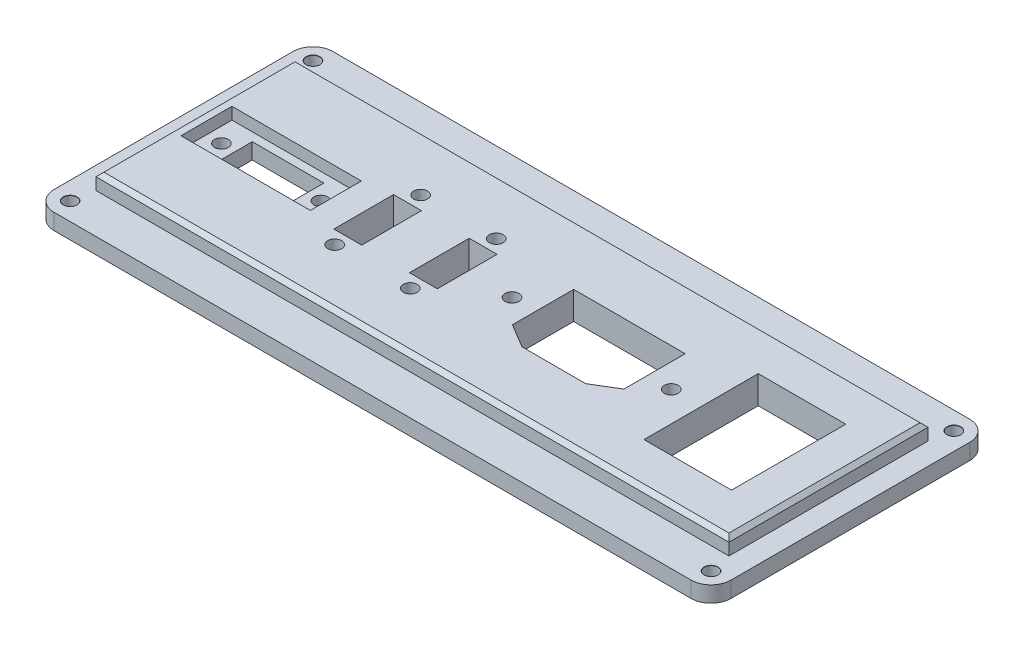
from build123d import *

# Parameters (mm, degrees)
SKETCH1_W                      = 170
SKETCH1_H                      = 70
BOSS_EXTRUDE1_DEPTH            = 4
SKETCH2_W                      = 159
SKETCH2_H                      = 50
BOSS_EXTRUDE2_DEPTH            = 4
M3_CLEARANCE_HOLE1_D           = 3.4
M3_CLEARANCE_HOLE1_CSINK_D     = 3.5
M3_CLEARANCE_HOLE1_CSINK_ANGLE = 90
SKETCH6_R                      = 1.75
SKETCH6_W                      = 18
SKETCH6_H                      = 8.5
SKETCH6_W_2                    = 22
SKETCH6_H_2                    = 28.7
SKETCH6_W_3                    = 7
SKETCH6_H_3                    = 15
CUT_EXTRUDE1_DEPTH             = 9
CUT_EXTRUDE2_START             = -8
SKETCH6_3_W                    = 18
SKETCH6_3_H                    = 8.5
SKETCH6_3_W_2                  = 32.5
SKETCH6_3_H_2                  = 12.8
CUT_EXTRUDE2_DEPTH             = 3
CHAMFER1_SIZE                  = 1
FILLET1_R                      = 5


with BuildPart() as part:
    # Sketch1 → Boss-Extrude1 (new body)
    with BuildSketch(Plane(origin=(0, 0, 0), x_dir=(1, 0, 0), z_dir=(0, 1, 0))):
        Rectangle(SKETCH1_W, SKETCH1_H)
    extrude(amount=BOSS_EXTRUDE1_DEPTH)

    # Sketch2 → Boss-Extrude2 (add)
    with BuildSketch(Plane(origin=(0, 4, 0), x_dir=(1, 0, 0), z_dir=(0, 1, 0))):
        Rectangle(SKETCH2_W, SKETCH2_H)
    extrude(amount=BOSS_EXTRUDE2_DEPTH)

    # M3 Clearance Hole1 (through all)
    with Locations(Plane(origin=(0, 4, 0), x_dir=(1, 0, 0), z_dir=(0, 1, 0))):
        with Locations((80.5, -30.5), (80.5, 30.5), (-80.5, -30.5), (-80.5, 30.5)):
            CounterSinkHole(M3_CLEARANCE_HOLE1_D / 2, M3_CLEARANCE_HOLE1_CSINK_D / 2, counter_sink_angle=M3_CLEARANCE_HOLE1_CSINK_ANGLE)

    # Sketch6 → Cut-Extrude1 (cut, through all)
    with BuildSketch(Plane.XZ):
        with Locations((-48, 0)):
            Circle(SKETCH6_R)
        with Locations((-73, 0)):
            Circle(SKETCH6_R)
        with Locations((-60.5, 0)):
            Rectangle(SKETCH6_W, SKETCH6_H)
        with Locations((-33.75, 10.8)):
            Circle(SKETCH6_R)
        with Locations((-33.75, -10.8)):
            Circle(SKETCH6_R)
        with Locations((-14.75, 10.8)):
            Circle(SKETCH6_R)
        with Locations((-14.75, -10.8)):
            Circle(SKETCH6_R)
        Circle(SKETCH6_R)
        with Locations((58.5, 0)):
            Rectangle(SKETCH6_W_2, SKETCH6_H_2)
        with Locations((-33.75, 0)):
            Rectangle(SKETCH6_W_3, SKETCH6_H_3)
        with Locations((-14.75, 0)):
            Rectangle(SKETCH6_W_3, SKETCH6_H_3)
        Polygon((28, 9.5), (34, 5.894448725), (34, -9.5), (6, -9.5), (6, 5.894448725), (12, 9.5), align=None)
        with Locations((40, 0)):
            Circle(SKETCH6_R)
    extrude(amount=-CUT_EXTRUDE1_DEPTH, mode=Mode.SUBTRACT)

    # Sketch6_3 → Cut-Extrude2 (cut)
    with BuildSketch(Plane.XZ.offset(CUT_EXTRUDE2_START)):
        with Locations((-60.5, 0)):
            Rectangle(SKETCH6_3_W, SKETCH6_3_H)
        with Locations((-60.5, 0)):
            Rectangle(SKETCH6_3_W_2, SKETCH6_3_H_2)
    extrude(amount=CUT_EXTRUDE2_DEPTH, mode=Mode.SUBTRACT)

    # Chamfer1
    chamfer1_edges = [part.edges().sort_by_distance(p)[0] for p in [
        (69.5, 0, 0),
        (58.5, 0, 14.35),
        (47.5, 0, 0),
        (58.5, 0, -14.35),
        (-37.25, 0, 0),
        (-33.75, 0, 7.5),
        (-33.75, 0, -7.5),
        (-30.25, 0, 0),
        (-18.25, 0, 0),
        (-14.75, 0, 7.5),
        (-14.75, 0, -7.5),
        (-11.25, 0, 0),
        (20, 0, 9.5),
        (31, 0, 7.697224362),
        (34, 0, -1.802775638),
        (20, 0, -9.5),
        (9, 0, 7.697224362),
        (6, 0, -1.802775638),
        (-79.5, 8, 0),
        (0, 8, -25),
        (0, 8, 25),
        (79.5, 8, 0),
        (-51.5, 0, 0),
        (-60.5, 0, 4.25),
        (-69.5, 0, 0),
        (-60.5, 0, -4.25),
    ]]
    chamfer(chamfer1_edges, length=CHAMFER1_SIZE)

    # Fillet1
    fillet1_edges = [part.edges().sort_by_distance(p)[0] for p in [
        (85, 2, 35),
        (-85, 2, 35),
        (-85, 2, -35),
        (85, 2, -35),
    ]]
    fillet(fillet1_edges, radius=FILLET1_R)


solid = part.part
